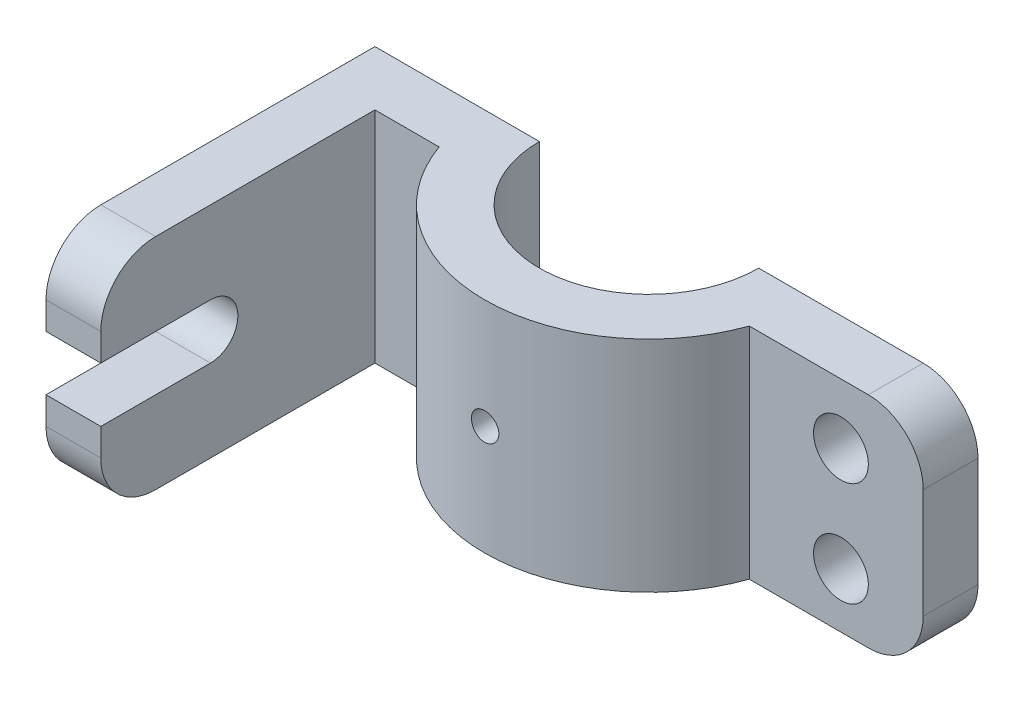
from build123d import *

# Parameters (mm, degrees)
SALIENTE_EXTRUIR1_DEPTH      = 25.4
SALIENTE_EXTRUIR1_DEPTH_BACK = 25.4
CROQUIS1_OUTSIDE_W           = 175.108
CROQUIS1_OUTSIDE_H           = 86.208
CROQUIS1_OUTSIDE_R           = 3.175
CROQUIS1_OUTSIDE_R_2         = 6.35
CORTAR_EXTRUIR1_DEPTH        = 38.1
CORTAR_EXTRUIR2_DEPTH        = 12.7


with BuildPart() as part:
    # Croquis2 → Saliente-Extruir1 (new, two sides: drawn at the far end of the back side and taken through both)
    with BuildSketch(Plane(origin=(0, 0, 0), x_dir=(1, 0, 0), z_dir=(0, 1, 0)).offset(-SALIENTE_EXTRUIR1_DEPTH_BACK)):
        with BuildLine():
            Line((-63.5, 0), (-25.4, 0))
            ThreePointArc((-25.4, 0), (0, -25.4), (25.4, 0))
            Line((25.4, 0), (76.2, 0))
            Line((76.2, 0), (76.2, -12.7))
            Line((76.2, -12.7), (35.921024484, -12.7))
            ThreePointArc((35.921024484, -12.7), (0, -38.1), (-35.921024484, -12.7))
            Line((-35.921024484, -12.7), (-50.8, -12.7))
            Line((-50.8, -12.7), (-50.8, -76.2))
            Line((-50.8, -76.2), (-63.5, -76.2))
            Line((-63.5, -76.2), (-63.5, 0))
        make_face()
    extrude(amount=SALIENTE_EXTRUIR1_DEPTH + SALIENTE_EXTRUIR1_DEPTH_BACK)

    # Croquis1 outside → Cortar-Extruir1 (cut)
    # profile 1 of 4: a face of its own
    with BuildSketch(Plane.XY):
        with Locations((6.35, 0)):
            Rectangle(CROQUIS1_OUTSIDE_W, CROQUIS1_OUTSIDE_H)
        with BuildLine():
            Line((76.2, 12.7), (76.2, -12.7))
            ThreePointArc((76.2, -12.7), (72.480256121, -21.680256121), (63.5, -25.4))
            Line((63.5, -25.4), (-63.5, -25.4))
            Line((-63.5, -25.4), (-63.5, 25.4))
            Line((-63.5, 25.4), (63.5, 25.4))
            ThreePointArc((63.5, 25.4), (72.480256121, 21.680256121), (76.2, 12.7))
        make_face(mode=Mode.SUBTRACT)
    # profile 2 of 4: a face of its own
    with BuildSketch(Plane.XY):
        Circle(CROQUIS1_OUTSIDE_R)
    # profile 3 of 4: a face of its own
    with BuildSketch(Plane.XY):
        with Locations((57.15, 11.454971957)):
            Circle(CROQUIS1_OUTSIDE_R_2)
    # profile 4 of 4: a face of its own
    with BuildSketch(Plane.XY):
        with Locations((57.15, -12.7)):
            Circle(CROQUIS1_OUTSIDE_R_2)
    extrude(amount=CORTAR_EXTRUIR1_DEPTH, mode=Mode.SUBTRACT)

    # Croquis3 → Cortar-Extruir2 (cut)
    with BuildSketch(Plane(origin=(-50.8, 0, 0), x_dir=(0, 0, -1), z_dir=(1, 0, 0))):
        with BuildLine():
            Line((-76.2, 6.35), (-50.8, 6.35))
            ThreePointArc((-50.8, 6.35), (-44.45, 0), (-50.8, -6.35))
            Line((-50.8, -6.35), (-76.2, -6.35))
            Line((-76.2, -6.35), (-76.2, 6.35))
        make_face()
        with BuildLine():
            Line((-63.5, 25.4), (-76.2, 25.4))
            Line((-76.2, 25.4), (-76.2, 12.7))
            ThreePointArc((-76.2, 12.7), (-72.480256121, 21.680256121), (-63.5, 25.4))
        make_face()
        with BuildLine():
            Line((-76.2, -12.7), (-76.2, -25.4))
            Line((-76.2, -25.4), (-63.5, -25.4))
            ThreePointArc((-63.5, -25.4), (-72.480256121, -21.680256121), (-76.2, -12.7))
        make_face()
    extrude(amount=-CORTAR_EXTRUIR2_DEPTH, mode=Mode.SUBTRACT)


solid = part.part
